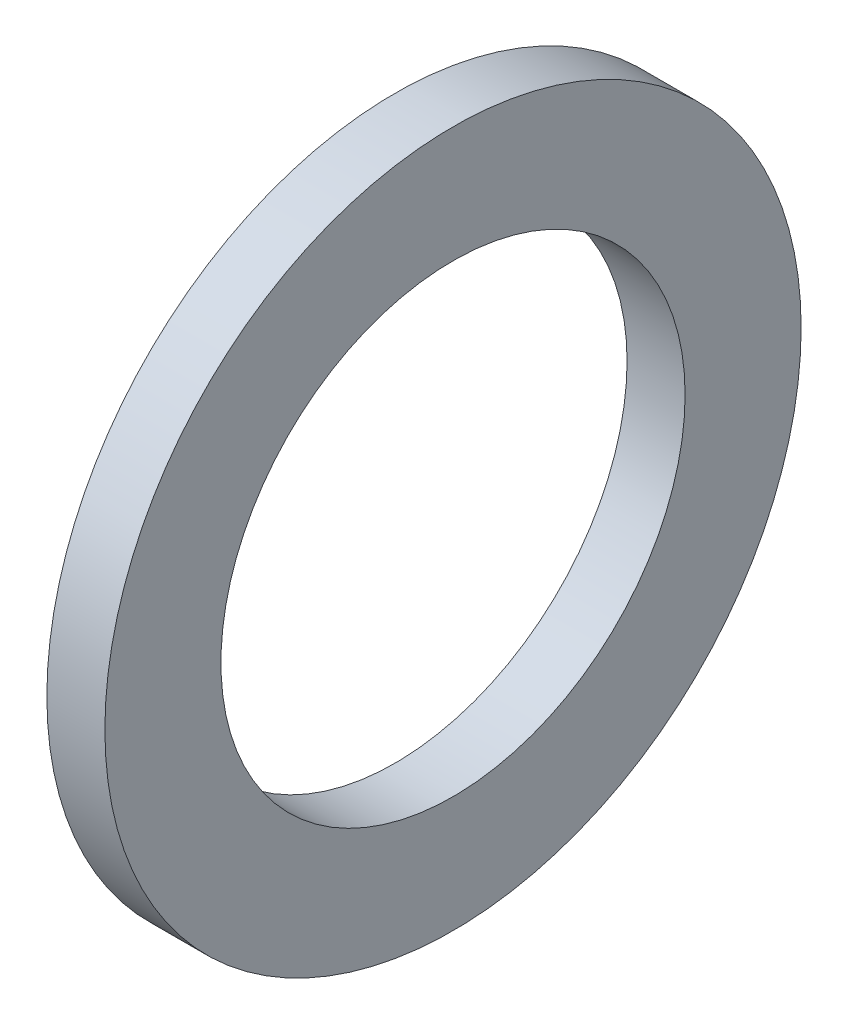
from build123d import *

# Parameters (mm, degrees)
SKETCH1_R           = 19.05
SKETCH1_R_2         = 12.7
BOSS_EXTRUDE1_DEPTH = 3.175


with BuildPart() as part:
    # Sketch1 → Boss-Extrude1 (new body)
    with BuildSketch(Plane(origin=(0, 0, 0), x_dir=(0, 0, -1), z_dir=(1, 0, 0))):
        Circle(SKETCH1_R)
        Circle(SKETCH1_R_2, mode=Mode.SUBTRACT)
    extrude(amount=BOSS_EXTRUDE1_DEPTH)


solid = part.part
